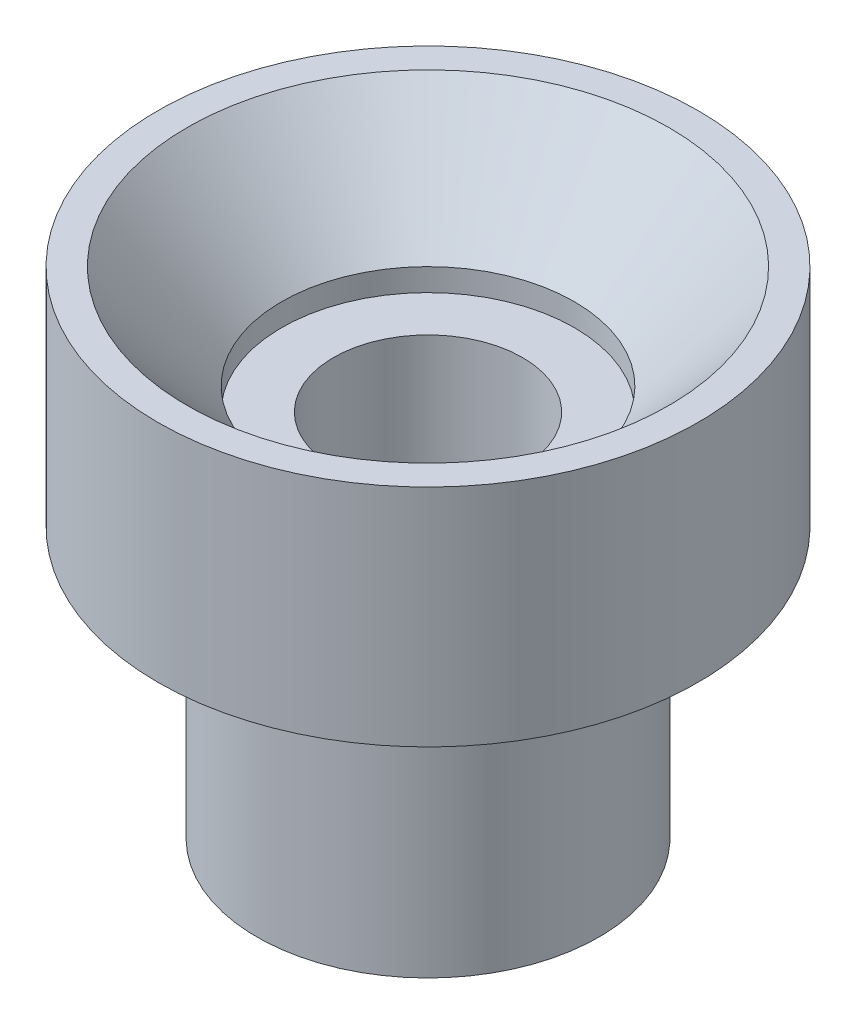
from build123d import *


with BuildPart() as part:
    # Sketch1 → Revolve1 (revolve)
    with BuildSketch(Plane.XY):
        Polygon((2.1, 0), (2.1, 8.2), (3.25, 8.2), (3.25, 8.7), (5.35, 11), (6, 11), (6, 6), (3.8, 6), (3.8, 0), align=None)
    revolve(axis=Axis((0, 0, 0), (0, 1, 0)))


solid = part.part
